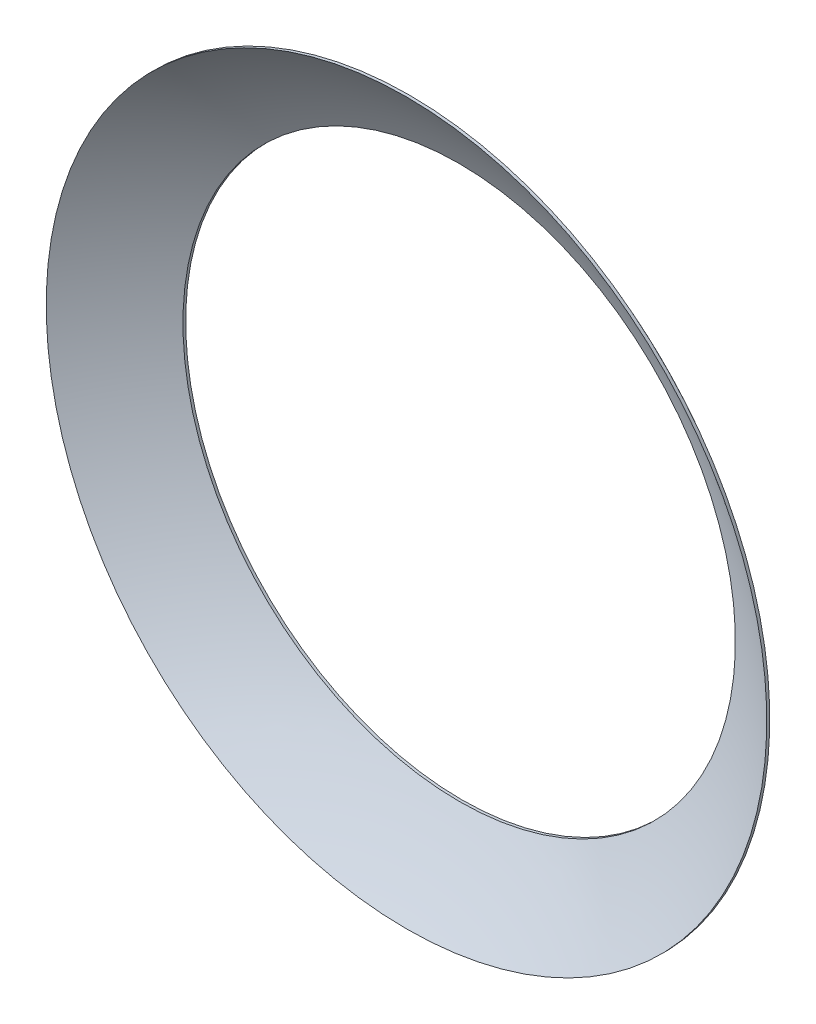
from build123d import *

# Parameters (mm, degrees)
REVOLVE_1_ANGLE      = 180
SHELL_1_T            = 0.5
SKETCH_2_OUTSIDE_W   = 328.82
SKETCH_2_OUTSIDE_H   = 328.82
SKETCH_2_OUTSIDE_R   = 75
SKETCH_2_OUTSIDE_R_2 = 57.5
CUT_EXTRUDE_1_DEPTH  = 323


with BuildPart() as part:
    # 草图1 → 旋转1 (revolve)
    with BuildSketch(Plane.XY):
        with BuildLine():
            Line((0, -125.2), (0, 125.2))
            ThreePointArc((0, 125.2), (-125.2, 0), (0, -125.2))
        make_face()
    revolve(axis=Axis((0, 175.755690027, 0), (0, -1, 0)), revolution_arc=REVOLVE_1_ANGLE)

    # 抽壳1
    shell_1_openings = [part.faces().sort_by_distance(p)[0] for p in [
        (0, 0, 0),
    ]]
    offset(amount=SHELL_1_T, openings=shell_1_openings)

    # 草图2 outside → 切除-拉伸1 (cut)
    with BuildSketch(Plane(origin=(0, 0, 0), x_dir=(1, 0, 0), z_dir=(0, 0, -1))):
        Rectangle(SKETCH_2_OUTSIDE_W, SKETCH_2_OUTSIDE_H)
        with Locations(Location((0, 0, 0), (0, 0, 90))):
            Circle(SKETCH_2_OUTSIDE_R, mode=Mode.SUBTRACT)
        with Locations(Location((0, 0, 0), (0, 0, 90))):
            Circle(SKETCH_2_OUTSIDE_R_2)
    extrude(amount=CUT_EXTRUDE_1_DEPTH, mode=Mode.SUBTRACT)


solid = part.part
